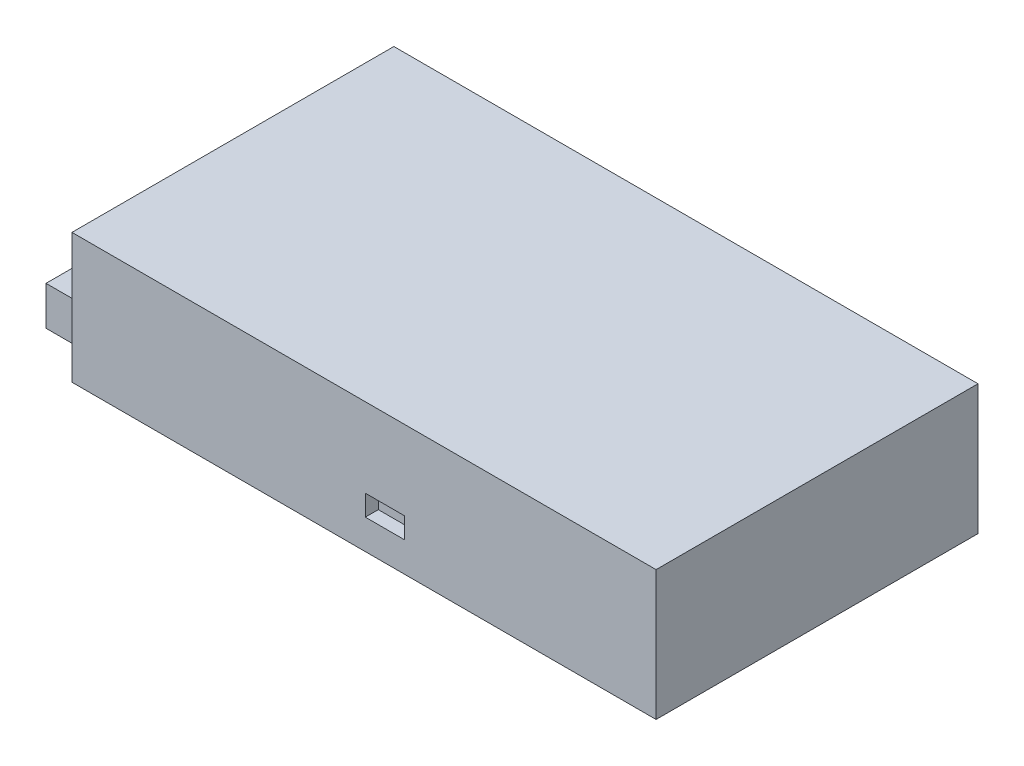
from build123d import *

# Parameters (mm, degrees)
SKETCH1_W           = 225
SKETCH1_H           = 124
BOSS_EXTRUDE1_DEPTH = 50
SKETCH3_R           = 2
CUT_EXTRUDE2_DEPTH  = 5
SKETCH4_W           = 15
SKETCH4_H           = 8
CUT_EXTRUDE3_DEPTH  = 5
SKETCH5_W           = 106
SKETCH5_H           = 15
BOSS_EXTRUDE2_DEPTH = 13


with BuildPart() as part:
    # Sketch1 → Boss-Extrude1 (new body)
    with BuildSketch(Plane(origin=(0, 0, 0), x_dir=(1, 0, 0), z_dir=(0, 1, 0))):
        Rectangle(SKETCH1_W, SKETCH1_H)
    extrude(amount=BOSS_EXTRUDE1_DEPTH)

    # Sketch3 → Cut-Extrude2 (cut)
    with BuildSketch(Plane.XZ):
        with Locations(Location((-79, -25.5, 0), (0, 0, 270))):  # turned: the seam where the file's is
            Circle(SKETCH3_R)
        with Locations(Location((-79, 24.5, 0), (0, 0, 270))):  # turned: the seam where the file's is
            Circle(SKETCH3_R)
        with Locations(Location((71, -25.5, 0), (0, 0, 270))):  # turned: the seam where the file's is
            Circle(SKETCH3_R)
        with Locations(Location((71, 24.5, 0), (0, 0, 270))):  # turned: the seam where the file's is
            Circle(SKETCH3_R)
    extrude(amount=-CUT_EXTRUDE2_DEPTH, mode=Mode.SUBTRACT)

    # Sketch4 → Cut-Extrude3 (cut)
    with BuildSketch(Plane.XY.offset(62)):
        with Locations((8, 15.5)):
            Rectangle(SKETCH4_W, SKETCH4_H)
    extrude(amount=-CUT_EXTRUDE3_DEPTH, mode=Mode.SUBTRACT)

    # Sketch5 → Boss-Extrude2 (add)
    with BuildSketch(Plane.ZY.offset(112.5)):
        with Locations((6, 17.5)):
            Rectangle(SKETCH5_W, SKETCH5_H)
    extrude(amount=BOSS_EXTRUDE2_DEPTH)


solid = part.part
